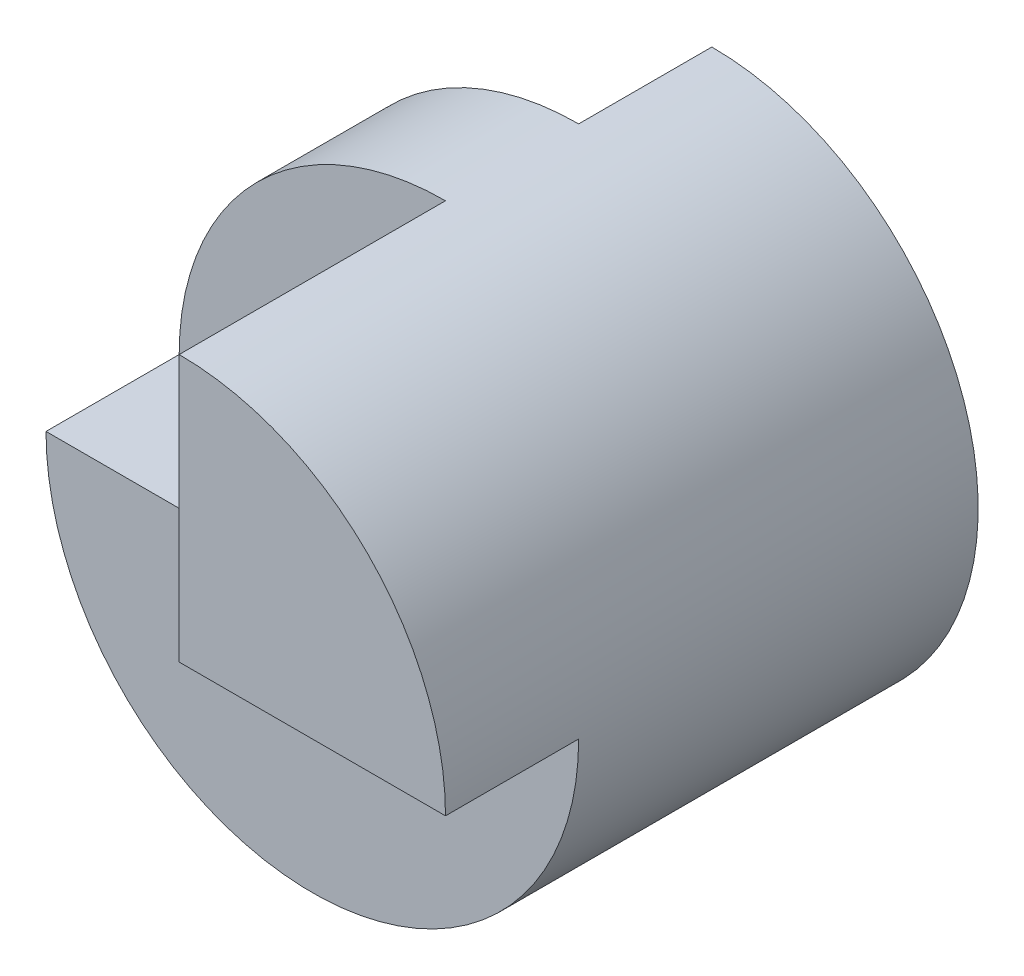
from build123d import *

# Parameters (mm, degrees)
SKETCH1_R               = 20
BOSS_EXTRUDE1_DEPTH     = 40
SKETCH2_W               = 20
SKETCH2_H               = 10
CUT_EXTRUDE1_DEPTH      = 40
CUT_EXTRUDE1_DEPTH_BACK = 40
SKETCH3_W               = 10
SKETCH3_H               = 20
CUT_EXTRUDE2_DEPTH      = 40
CUT_EXTRUDE3_DEPTH      = 10


with BuildPart() as part:
    # Sketch1 → Boss-Extrude1 (new body)
    with BuildSketch(Plane.XY):
        Circle(SKETCH1_R)
    extrude(amount=BOSS_EXTRUDE1_DEPTH)

    # Sketch2 → Cut-Extrude1 (cut, two sides)
    with BuildSketch(Plane(origin=(0, 0, 0), x_dir=(1, 0, 0), z_dir=(0, 1, 0))) as cut_extrude1_sk:
        with Locations((-10, -5)):
            Rectangle(SKETCH2_W, SKETCH2_H)
        with Locations((-10, -35)):
            Rectangle(SKETCH2_W, SKETCH2_H)
    extrude(amount=CUT_EXTRUDE1_DEPTH, mode=Mode.SUBTRACT)
    extrude(cut_extrude1_sk.sketch, amount=-CUT_EXTRUDE1_DEPTH_BACK, mode=Mode.SUBTRACT)

    # Sketch3 → Cut-Extrude2 (cut)
    with BuildSketch(Plane.ZY):
        with Locations((35, -10)):
            Rectangle(SKETCH3_W, SKETCH3_H)
    extrude(amount=-CUT_EXTRUDE2_DEPTH, mode=Mode.SUBTRACT)

    # Sketch4 → Cut-Extrude3 (cut)
    with BuildSketch(Plane.XY.offset(30)):
        with BuildLine():
            Line((-20, 0), (0, 0))
            Line((0, 0), (0, 20))
            ThreePointArc((0, 20), (-14.142135624, 14.142135624), (-20, 0))
        make_face()
    extrude(amount=-CUT_EXTRUDE3_DEPTH, mode=Mode.SUBTRACT)


solid = part.part
